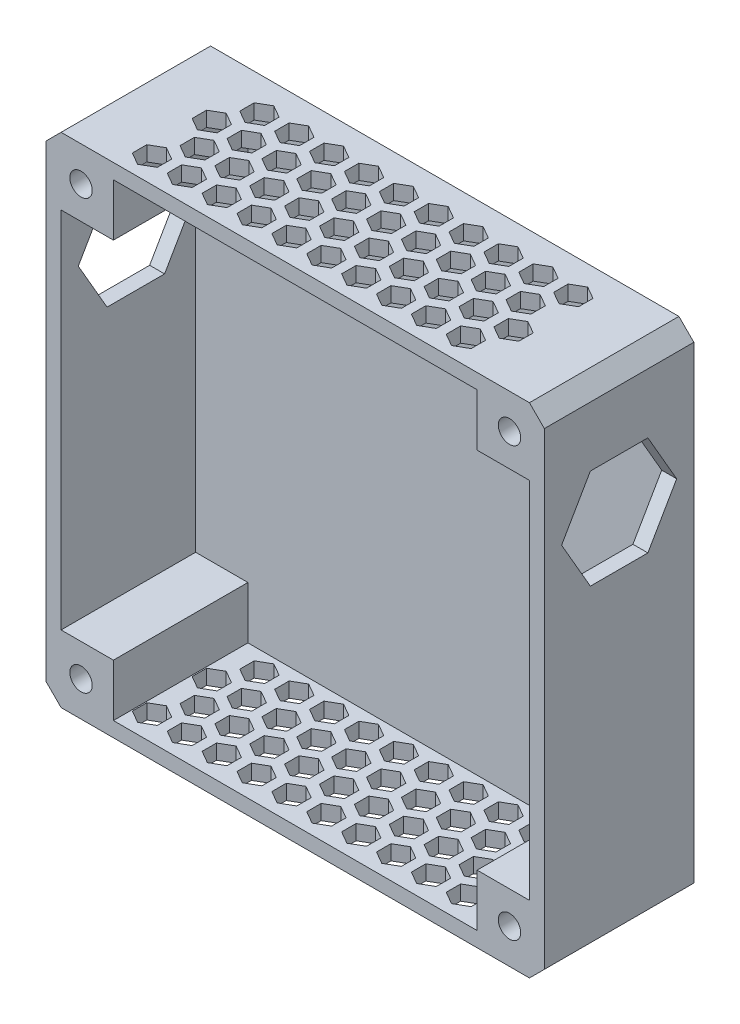
from build123d import *

# Parameters (mm, degrees)
SKETCH2_W           = 100
SKETCH2_H           = 100
BOSS_EXTRUDE1_DEPTH = 3
SKETCH3_W           = 100
SKETCH3_H           = 100
BOSS_EXTRUDE2_DEPTH = 27
CUT_EXTRUDE1_DEPTH  = 128.950768134
CUT_EXTRUDE2_DEPTH  = 149.990222737
CUT_EXTRUDE3_DEPTH  = 15
SKETCH7_3_R         = 2.25
CUT_EXTRUDE4_DEPTH  = 133.926617113
SKETCH8_R           = 2.65
BOSS_EXTRUDE3_DEPTH = 15
CHAMFER1_SIZE       = 3


with BuildPart() as part:
    # Sketch2 → Boss-Extrude1 (new body)
    with BuildSketch(Plane.XY):
        with Locations((23.968906076, -56.292457263)):
            Rectangle(SKETCH2_W, SKETCH2_H)
    extrude(amount=BOSS_EXTRUDE1_DEPTH)

    # Sketch3 → Boss-Extrude2 (add)
    with BuildSketch(Plane.XY.offset(3)):
        with Locations((23.968906076, -56.292457263)):
            Rectangle(SKETCH3_W, SKETCH3_H)
        Polygon((-12.531093924, -9.292457263), (60.468906076, -9.292457263), (60.468906076, -19.792457263), (70.968906076, -19.792457263), (70.968906076, -92.792457263), (60.468906076, -92.792457263), (60.468906076, -103.292457263), (-12.531093924, -103.292457263), (-12.531093924, -92.792457263), (-23.031093924, -92.792457263), (-23.031093924, -19.792457263), (-12.531093924, -19.792457263), align=None, mode=Mode.SUBTRACT)
    extrude(amount=BOSS_EXTRUDE2_DEPTH)

    # Sketch5 → Cut-Extrude1 (cut, through all)
    with BuildSketch(Plane.XZ.offset(106.292457263)):
        Polygon((-9.781093924, 27.886751346), (-12.281093924, 26.443375673), (-12.281093924, 23.556624327), (-9.781093924, 22.113248654), (-7.281093924, 23.556624327), (-7.281093924, 26.443375673), align=None)
        Polygon((-0.281093924, 23.556624327), (-0.281093924, 26.443375673), (-2.781093924, 27.886751346), (-5.281093924, 26.443375673), (-5.281093924, 23.556624327), (-2.781093924, 22.113248654), align=None)
        Polygon((-6.281093924, 21.824573519), (-8.781093924, 20.381197846), (-8.781093924, 17.494446501), (-6.281093924, 16.051070828), (-3.781093924, 17.494446501), (-3.781093924, 20.381197846), align=None)
        Polygon((3.218906076, 20.381197846), (0.718906076, 21.824573519), (-1.781093924, 20.381197846), (-1.781093924, 17.494446501), (0.718906076, 16.051070828), (3.218906076, 17.494446501), align=None)
        Polygon((6.718906076, 23.556624327), (6.718906076, 26.443375673), (4.218906076, 27.886751346), (1.718906076, 26.443375673), (1.718906076, 23.556624327), (4.218906076, 22.113248654), align=None)
        Polygon((10.218906076, 20.381197846), (7.718906076, 21.824573519), (5.218906076, 20.381197846), (5.218906076, 17.494446501), (7.718906076, 16.051070828), (10.218906076, 17.494446501), align=None)
        Polygon((13.718906076, 23.556624327), (13.718906076, 26.443375673), (11.218906076, 27.886751346), (8.718906076, 26.443375673), (8.718906076, 23.556624327), (11.218906076, 22.113248654), align=None)
        Polygon((17.218906076, 20.381197846), (14.718906076, 21.824573519), (12.218906076, 20.381197846), (12.218906076, 17.494446501), (14.718906076, 16.051070828), (17.218906076, 17.494446501), align=None)
        Polygon((20.718906076, 23.556624327), (20.718906076, 26.443375673), (18.218906076, 27.886751346), (15.718906076, 26.443375673), (15.718906076, 23.556624327), (18.218906076, 22.113248654), align=None)
        Polygon((24.218906076, 20.381197846), (21.718906076, 21.824573519), (19.218906076, 20.381197846), (19.218906076, 17.494446501), (21.718906076, 16.051070828), (24.218906076, 17.494446501), align=None)
        Polygon((27.718906076, 23.556624327), (27.718906076, 26.443375673), (25.218906076, 27.886751346), (22.718906076, 26.443375673), (22.718906076, 23.556624327), (25.218906076, 22.113248654), align=None)
        Polygon((31.218906076, 20.381197846), (28.718906076, 21.824573519), (26.218906076, 20.381197846), (26.218906076, 17.494446501), (28.718906076, 16.051070828), (31.218906076, 17.494446501), align=None)
        Polygon((34.718906076, 23.556624327), (34.718906076, 26.443375673), (32.218906076, 27.886751346), (29.718906076, 26.443375673), (29.718906076, 23.556624327), (32.218906076, 22.113248654), align=None)
        Polygon((38.218906076, 20.381197846), (35.718906076, 21.824573519), (33.218906076, 20.381197846), (33.218906076, 17.494446501), (35.718906076, 16.051070828), (38.218906076, 17.494446501), align=None)
        Polygon((41.718906076, 23.556624327), (41.718906076, 26.443375673), (39.218906076, 27.886751346), (36.718906076, 26.443375673), (36.718906076, 23.556624327), (39.218906076, 22.113248654), align=None)
        Polygon((45.218906076, 20.381197846), (42.718906076, 21.824573519), (40.218906076, 20.381197846), (40.218906076, 17.494446501), (42.718906076, 16.051070828), (45.218906076, 17.494446501), align=None)
        Polygon((48.718906076, 23.556624327), (48.718906076, 26.443375673), (46.218906076, 27.886751346), (43.718906076, 26.443375673), (43.718906076, 23.556624327), (46.218906076, 22.113248654), align=None)
        Polygon((52.218906076, 20.381197846), (49.718906076, 21.824573519), (47.218906076, 20.381197846), (47.218906076, 17.494446501), (49.718906076, 16.051070828), (52.218906076, 17.494446501), align=None)
        Polygon((55.718906076, 23.556624327), (55.718906076, 26.443375673), (53.218906076, 27.886751346), (50.718906076, 26.443375673), (50.718906076, 23.556624327), (53.218906076, 22.113248654), align=None)
        Polygon((59.218906076, 20.381197846), (56.718906076, 21.824573519), (54.218906076, 20.381197846), (54.218906076, 17.494446501), (56.718906076, 16.051070828), (59.218906076, 17.494446501), align=None)
        Polygon((-0.281093924, 11.556624327), (-0.281093924, 14.443375673), (-2.781093924, 15.886751346), (-5.281093924, 14.443375673), (-5.281093924, 11.556624327), (-2.781093924, 10.113248654), align=None)
        Polygon((3.218906076, 8.381197846), (0.718906076, 9.824573519), (-1.781093924, 8.381197846), (-1.781093924, 5.494446501), (0.718906076, 4.051070828), (3.218906076, 5.494446501), align=None)
        Polygon((6.718906076, 11.556624327), (6.718906076, 14.443375673), (4.218906076, 15.886751346), (1.718906076, 14.443375673), (1.718906076, 11.556624327), (4.218906076, 10.113248654), align=None)
        Polygon((10.218906076, 8.381197846), (7.718906076, 9.824573519), (5.218906076, 8.381197846), (5.218906076, 5.494446501), (7.718906076, 4.051070828), (10.218906076, 5.494446501), align=None)
        Polygon((13.718906076, 11.556624327), (13.718906076, 14.443375673), (11.218906076, 15.886751346), (8.718906076, 14.443375673), (8.718906076, 11.556624327), (11.218906076, 10.113248654), align=None)
        Polygon((17.218906076, 8.381197846), (14.718906076, 9.824573519), (12.218906076, 8.381197846), (12.218906076, 5.494446501), (14.718906076, 4.051070828), (17.218906076, 5.494446501), align=None)
        Polygon((20.718906076, 11.556624327), (20.718906076, 14.443375673), (18.218906076, 15.886751346), (15.718906076, 14.443375673), (15.718906076, 11.556624327), (18.218906076, 10.113248654), align=None)
        Polygon((24.218906076, 8.381197846), (21.718906076, 9.824573519), (19.218906076, 8.381197846), (19.218906076, 5.494446501), (21.718906076, 4.051070828), (24.218906076, 5.494446501), align=None)
        Polygon((27.718906076, 11.556624327), (27.718906076, 14.443375673), (25.218906076, 15.886751346), (22.718906076, 14.443375673), (22.718906076, 11.556624327), (25.218906076, 10.113248654), align=None)
        Polygon((31.218906076, 8.381197846), (28.718906076, 9.824573519), (26.218906076, 8.381197846), (26.218906076, 5.494446501), (28.718906076, 4.051070828), (31.218906076, 5.494446501), align=None)
        Polygon((34.718906076, 11.556624327), (34.718906076, 14.443375673), (32.218906076, 15.886751346), (29.718906076, 14.443375673), (29.718906076, 11.556624327), (32.218906076, 10.113248654), align=None)
        Polygon((38.218906076, 8.381197846), (35.718906076, 9.824573519), (33.218906076, 8.381197846), (33.218906076, 5.494446501), (35.718906076, 4.051070828), (38.218906076, 5.494446501), align=None)
        Polygon((41.718906076, 11.556624327), (41.718906076, 14.443375673), (39.218906076, 15.886751346), (36.718906076, 14.443375673), (36.718906076, 11.556624327), (39.218906076, 10.113248654), align=None)
        Polygon((45.218906076, 8.381197846), (42.718906076, 9.824573519), (40.218906076, 8.381197846), (40.218906076, 5.494446501), (42.718906076, 4.051070828), (45.218906076, 5.494446501), align=None)
        Polygon((48.718906076, 11.556624327), (48.718906076, 14.443375673), (46.218906076, 15.886751346), (43.718906076, 14.443375673), (43.718906076, 11.556624327), (46.218906076, 10.113248654), align=None)
        Polygon((52.218906076, 8.381197846), (49.718906076, 9.824573519), (47.218906076, 8.381197846), (47.218906076, 5.494446501), (49.718906076, 4.051070828), (52.218906076, 5.494446501), align=None)
        Polygon((55.718906076, 11.556624327), (55.718906076, 14.443375673), (53.218906076, 15.886751346), (50.718906076, 14.443375673), (50.718906076, 11.556624327), (53.218906076, 10.113248654), align=None)
        Polygon((59.218906076, 8.381197846), (56.718906076, 9.824573519), (54.218906076, 8.381197846), (54.218906076, 5.494446501), (56.718906076, 4.051070828), (59.218906076, 5.494446501), align=None)
        Polygon((-7.281093924, 11.556624327), (-7.281093924, 14.443375673), (-9.781093924, 15.886751346), (-12.281093924, 14.443375673), (-12.281093924, 11.556624327), (-9.781093924, 10.113248654), align=None)
        Polygon((-3.781093924, 8.381197846), (-6.281093924, 9.824573519), (-8.781093924, 8.381197846), (-8.781093924, 5.494446501), (-6.281093924, 4.051070828), (-3.781093924, 5.494446501), align=None)
    extrude(amount=-CUT_EXTRUDE1_DEPTH, mode=Mode.SUBTRACT)

    # Sketch6 → Cut-Extrude2 (cut, through all)
    with BuildSketch(Plane(origin=(73.968906076, 0, 0), x_dir=(0, 0, -1), z_dir=(1, 0, 0))):
        Polygon((-26.547005384, -31.292457263), (-20.773502692, -41.292457263), (-9.226497308, -41.292457263), (-3.452994616, -31.292457263), (-9.226497308, -21.292457263), (-20.773502692, -21.292457263), align=None)
    extrude(amount=-CUT_EXTRUDE2_DEPTH, mode=Mode.SUBTRACT)

    # Sketch7 → Cut-Extrude3 (cut)
    with BuildSketch(Plane(origin=(0, 0, 0), x_dir=(-1, 0, 0), z_dir=(0, 0, -1))):
        Polygon((-69.566982287, -94.792457263), (-72.165058498, -99.292457263), (-69.566982287, -103.792457263), (-64.370829864, -103.792457263), (-61.772753653, -99.292457263), (-64.370829864, -94.792457263), align=None)
        Polygon((24.227246347, -99.292457263), (21.629170136, -94.792457263), (16.433017713, -94.792457263), (13.834941502, -99.292457263), (16.433017713, -103.792457263), (21.629170136, -103.792457263), align=None)
        Polygon((21.629170136, -17.792457263), (24.227246347, -13.292457263), (21.629170136, -8.792457263), (16.433017713, -8.792457263), (13.834941502, -13.292457263), (16.433017713, -17.792457263), align=None)
        Polygon((-69.566982287, -17.792457263), (-64.370829864, -17.792457263), (-61.772753653, -13.292457263), (-64.370829864, -8.792457263), (-69.566982287, -8.792457263), (-72.165058498, -13.292457263), align=None)
    extrude(amount=-CUT_EXTRUDE3_DEPTH, mode=Mode.SUBTRACT)

    # Sketch7_3 → Cut-Extrude4 (cut, through all)
    with BuildSketch(Plane(origin=(0, 0, 0), x_dir=(-1, 0, 0), z_dir=(0, 0, -1))):
        with Locations((-66.968906076, -13.292457263)):
            Circle(SKETCH7_3_R)
        with Locations((19.031093924, -13.292457263)):
            Circle(SKETCH7_3_R)
        with Locations((19.031093924, -99.292457263)):
            Circle(SKETCH7_3_R)
        with Locations((-66.968906076, -99.292457263)):
            Circle(SKETCH7_3_R)
    extrude(amount=-CUT_EXTRUDE4_DEPTH, mode=Mode.SUBTRACT)

    # Sketch8 → Boss-Extrude3 (add)
    with BuildSketch(Plane(origin=(0, 0, 15), x_dir=(-1, 0, 0), z_dir=(0, 0, -1))):
        with Locations((-66.968906076, -13.292457263)):
            Circle(SKETCH8_R)
        with Locations((19.031093924, -13.292457263)):
            Circle(SKETCH8_R)
        with Locations((-66.968906076, -99.292457263)):
            Circle(SKETCH8_R)
        with Locations((19.031093924, -99.292457263)):
            Circle(SKETCH8_R)
    extrude(amount=BOSS_EXTRUDE3_DEPTH)

    # Chamfer1
    chamfer1_edges = [part.edges().sort_by_distance(p)[0] for p in [
        (73.968906076, -106.292457263, 15),
        (73.968906076, -6.292457263, 15),
        (-26.031093924, -6.292457263, 15),
        (-26.031093924, -106.292457263, 15),
    ]]
    chamfer(chamfer1_edges, length=CHAMFER1_SIZE)


solid = part.part
